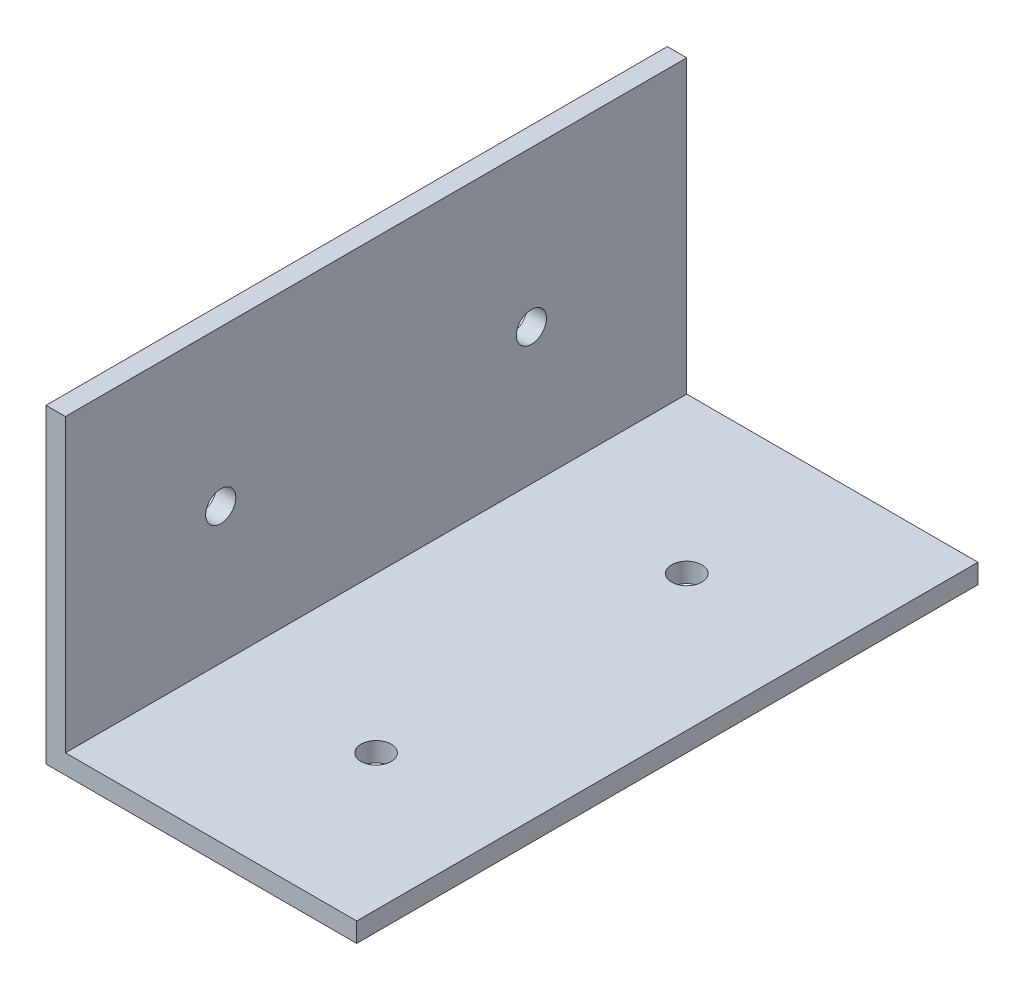
from build123d import *

# Parameters (mm, degrees)
BOSS_EXTRUDE1_DEPTH = 101.6
SKETCH2_R           = 2.4638
CUT_EXTRUDE1_DEPTH  = 6.35
SKETCH3_R           = 2.4638
CUT_EXTRUDE2_DEPTH  = 6.35


with BuildPart() as part:
    # Sketch1 → Boss-Extrude1 (new body)
    with BuildSketch(Plane.XY):
        Polygon((0, 0), (0, 47.625), (-3.175, 47.625), (-3.175, -3.175), (47.625, -3.175), (47.625, 0), align=None)
    extrude(amount=BOSS_EXTRUDE1_DEPTH)

    # Sketch2 → Cut-Extrude1 (cut)
    with BuildSketch(Plane(origin=(0, 0, 0), x_dir=(1, 0, 0), z_dir=(0, 1, 0))):
        with Locations((25.4, -76.2)):
            Circle(SKETCH2_R)
        with Locations((25.4, -25.4)):
            Circle(SKETCH2_R)
    extrude(amount=-CUT_EXTRUDE1_DEPTH, mode=Mode.SUBTRACT)

    # Sketch3 → Cut-Extrude2 (cut)
    with BuildSketch(Plane(origin=(0, 0, 0), x_dir=(0, 0, -1), z_dir=(1, 0, 0))):
        with Locations((-25.4, 22.225)):
            Circle(SKETCH3_R)
        with Locations((-76.2, 22.225)):
            Circle(SKETCH3_R)
    extrude(amount=-CUT_EXTRUDE2_DEPTH, mode=Mode.SUBTRACT)


solid = part.part
